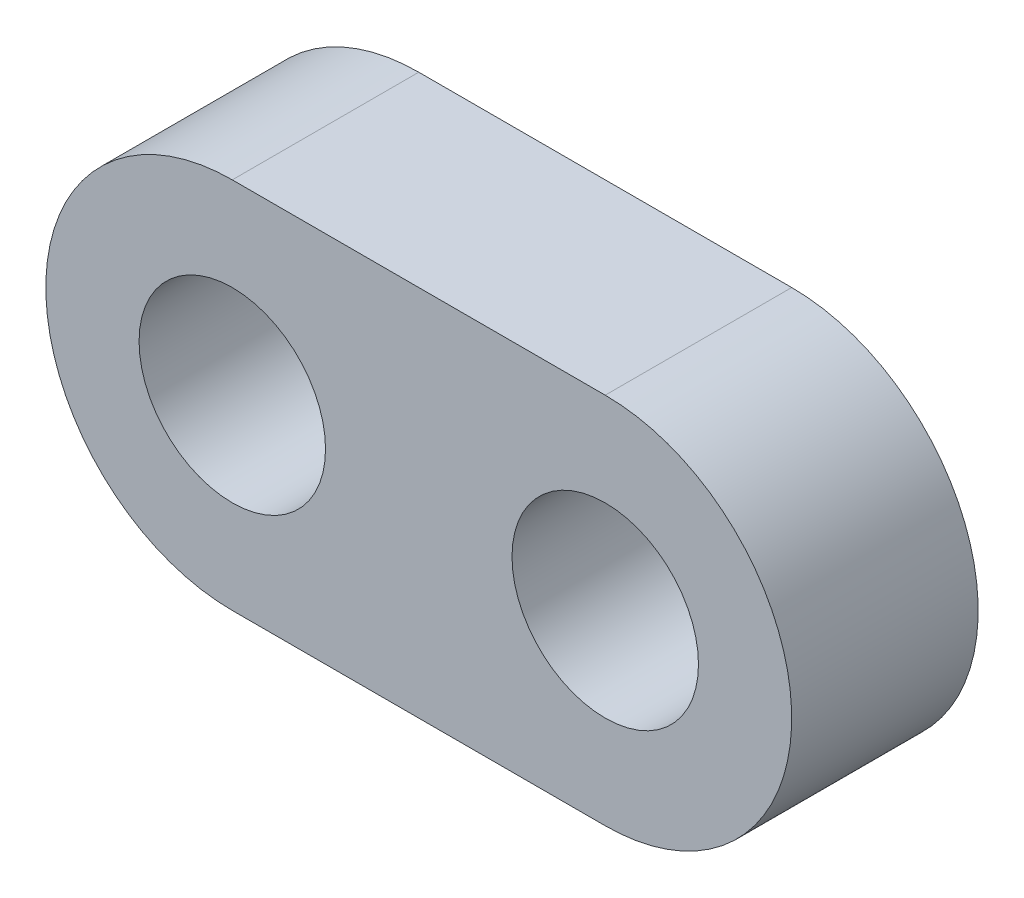
from build123d import *

# Parameters (mm, degrees)
SKETCH1_R           = 3.175
BOSS_EXTRUDE1_DEPTH = 6.35


with BuildPart() as part:
    # Sketch1 → Boss-Extrude1 (new body)
    with BuildSketch(Plane.XY):
        with BuildLine():
            Line((0, 6.35), (-12.7, 6.35))
            ThreePointArc((-12.7, 6.35), (-19.05, 0), (-12.7, -6.35))
            Line((-12.7, -6.35), (0, -6.35))
            ThreePointArc((0, -6.35), (6.35, 0), (0, 6.35))
        make_face()
        Circle(SKETCH1_R, mode=Mode.SUBTRACT)
        with Locations((-12.7, 0)):
            Circle(SKETCH1_R, mode=Mode.SUBTRACT)
    extrude(amount=BOSS_EXTRUDE1_DEPTH)


solid = part.part
